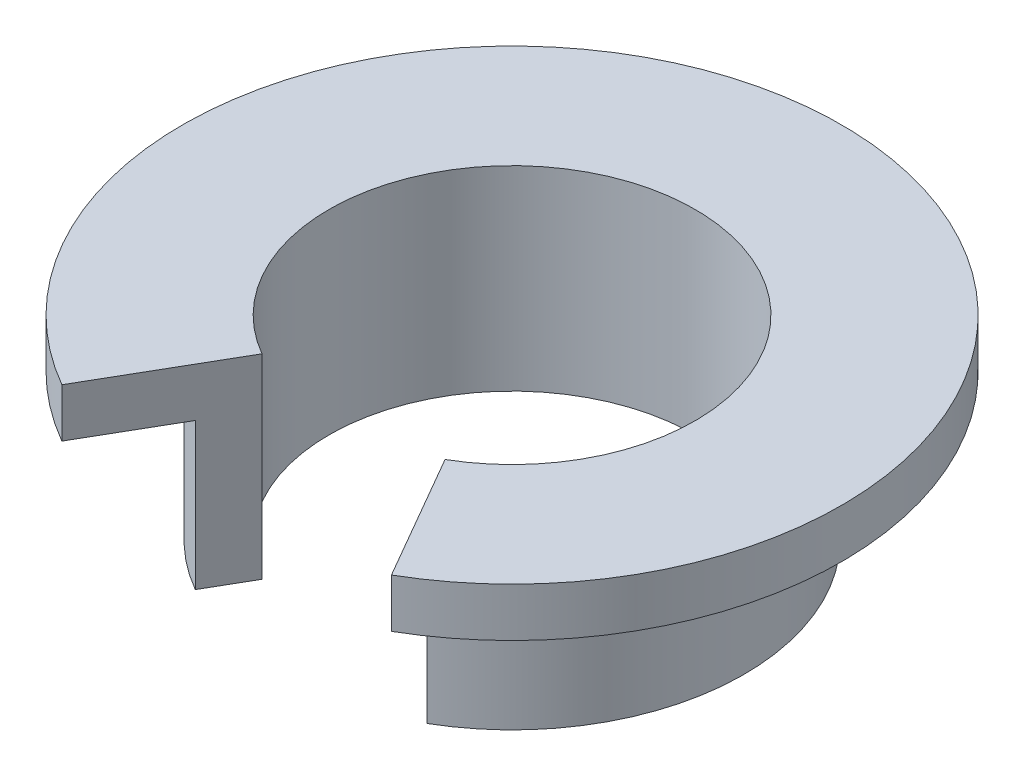
from build123d import *

# Parameters (mm, degrees)
CUT_EXTRUDE1_DEPTH = 10
SCALE1_SCALE       = 0.5


with BuildPart() as part:
    # Sketch1 → Revolve1 (revolve)
    with BuildSketch(Plane.XY):
        Polygon((7.5, 0), (7.5, 8), (13.5, 8), (13.5, 6), (9.5, 6), (9.5, 0), align=None)
    revolve(axis=Axis((0, 0, 0), (0, 1, 0)))

    # Sketch2 → Cut-Extrude1 (cut)
    with BuildSketch(Plane(origin=(0, 0, 0), x_dir=(1, 0, 0), z_dir=(0, 1, 0))):
        Polygon((-9.091166867, -15.746362913), (0, 0), (8.625529774, -14.939855811), align=None)
    extrude(amount=CUT_EXTRUDE1_DEPTH, mode=Mode.SUBTRACT)


with BuildPart() as part_1:
    # Scale1: scaled about (0, 0, 0)
    add(part.part.scale(SCALE1_SCALE))


solid = part_1.part
